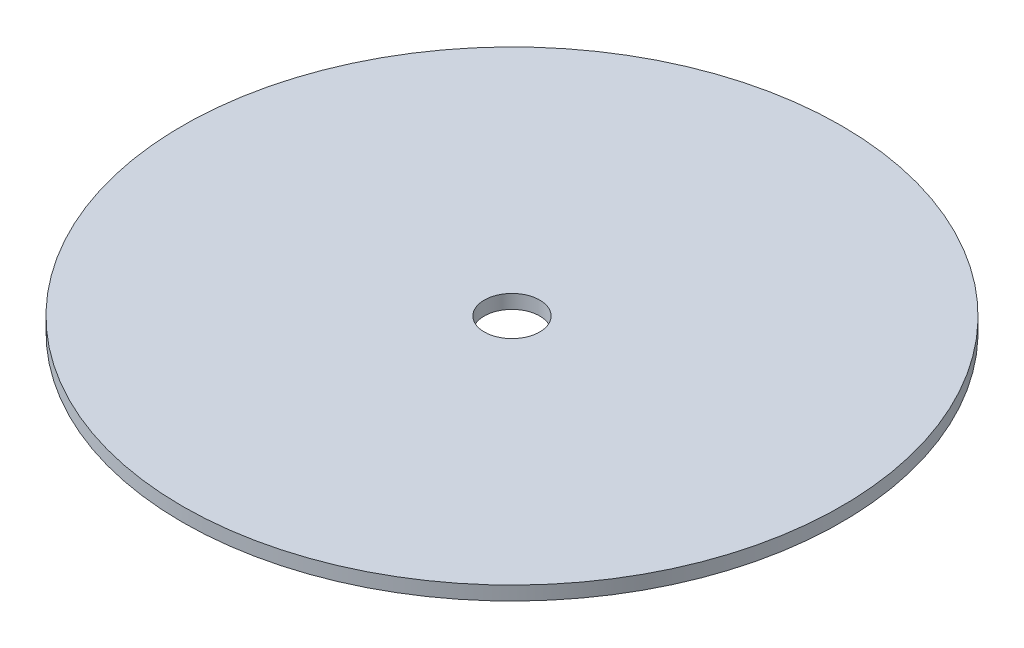
from build123d import *

# Parameters (mm, degrees)
SKETCH1_R               = 75.565
BOSS_EXTRUDE1_DEPTH     = 3.175
SKETCH3_R               = 6.35
CUT_EXTRUDE1_DEPTH      = 1
CUT_EXTRUDE1_DEPTH_BACK = 4.175


with BuildPart() as part:
    # Sketch1 → Boss-Extrude1 (new body)
    with BuildSketch(Plane(origin=(0, 0, 0), x_dir=(1, 0, 0), z_dir=(0, 1, 0))):
        Circle(SKETCH1_R)
    extrude(amount=BOSS_EXTRUDE1_DEPTH)

    # Sketch3 → Cut-Extrude1 (cut, two sides)
    with BuildSketch(Plane(origin=(0, 3.175, 0), x_dir=(1, 0, 0), z_dir=(0, 1, 0))) as cut_extrude1_sk:
        Circle(SKETCH3_R)
    extrude(amount=CUT_EXTRUDE1_DEPTH, mode=Mode.SUBTRACT)
    extrude(cut_extrude1_sk.sketch, amount=-CUT_EXTRUDE1_DEPTH_BACK, mode=Mode.SUBTRACT)


solid = part.part
